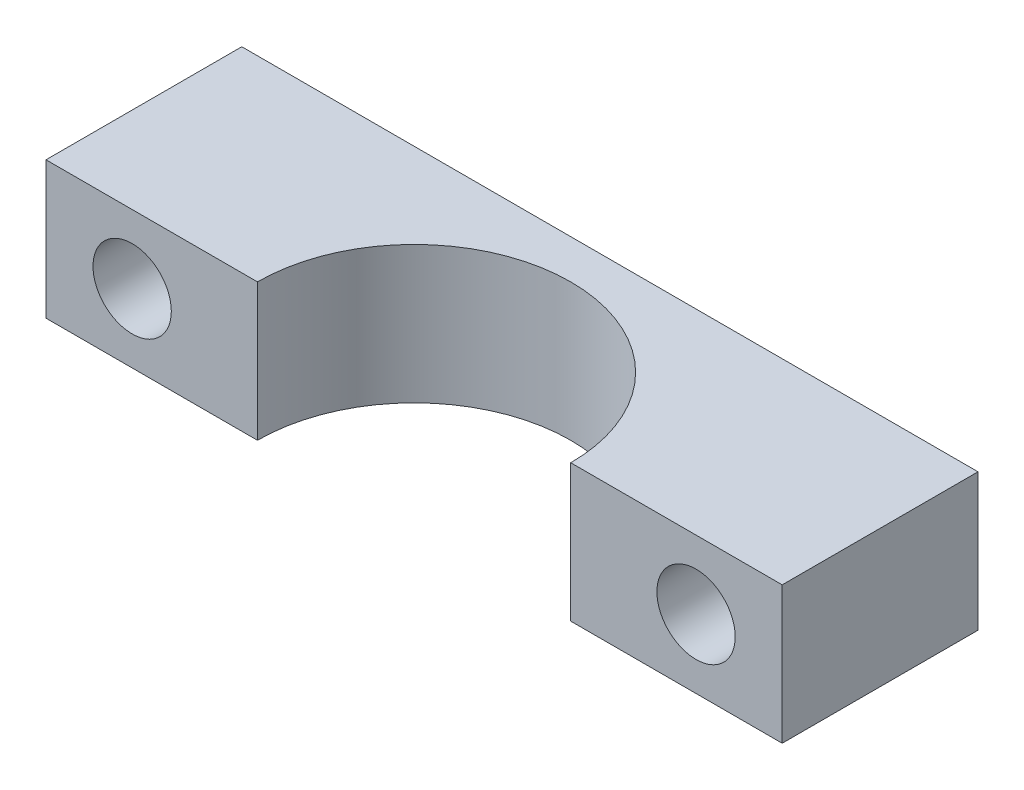
from build123d import *

# Parameters (mm, degrees)
BOSS_EXTRUDE1_DEPTH = 5.5626
SKETCH2_R           = 3.175
CUT_EXTRUDE1_DEPTH  = 16.875


with BuildPart() as part:
    # Sketch1 → Boss-Extrude1 (new body, symmetric)
    with BuildSketch(Plane(origin=(0, 0, 0), x_dir=(1, 0, 0), z_dir=(0, 1, 0))):
        with BuildLine():
            Line((-12.7, 0), (-29.845, 0))
            Line((-29.845, 0), (-29.845, 15.875))
            Line((-29.845, 15.875), (29.845, 15.875))
            Line((29.845, 15.875), (29.845, 0))
            Line((29.845, 0), (12.7, 0))
            ThreePointArc((12.7, 0), (0, 12.7), (-12.7, 0))
        make_face()
    extrude(amount=BOSS_EXTRUDE1_DEPTH, both=True)

    # Sketch2 → Cut-Extrude1 (cut, through all)
    with BuildSketch(Plane.XY):
        with Locations((-22.86, 0)):
            Circle(SKETCH2_R)
        with Locations((22.86, 0)):
            Circle(SKETCH2_R)
    extrude(amount=-CUT_EXTRUDE1_DEPTH, mode=Mode.SUBTRACT)


solid = part.part
